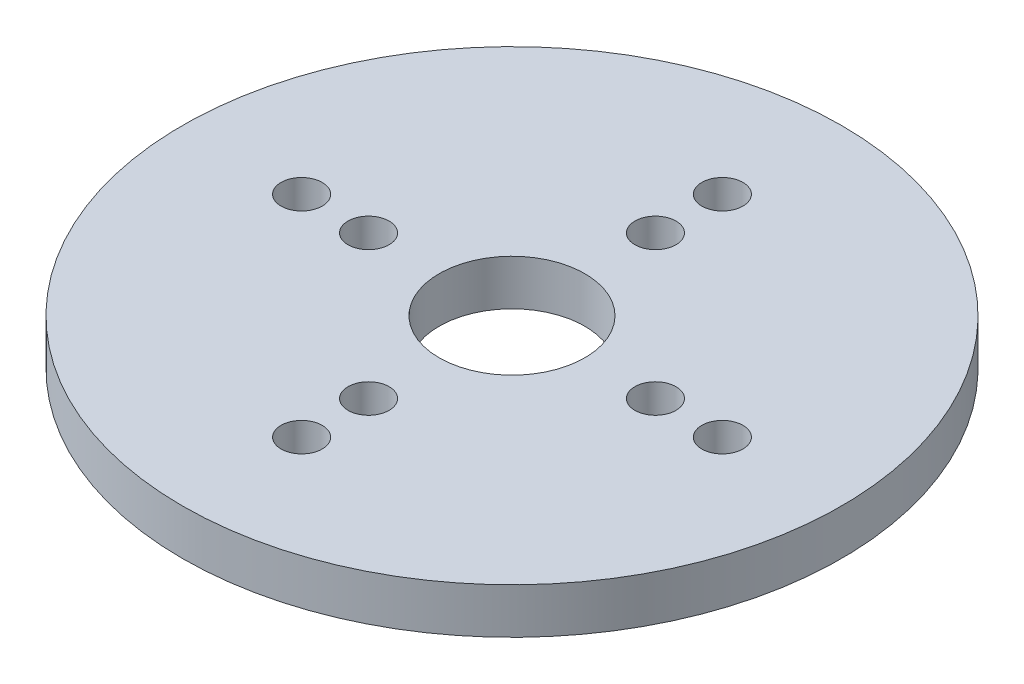
from build123d import *

# Parameters (mm, degrees)
SKETCH1_R           = 34.464858416
SKETCH1_R_2         = 2.15
SKETCH1_R_3         = 7.62
BOSS_EXTRUDE1_DEPTH = 4.7625


with BuildPart() as part:
    # Sketch1 → Boss-Extrude1 (new body)
    with BuildSketch(Plane(origin=(0, 0, 0), x_dir=(1, 0, 0), z_dir=(0, 1, 0))):
        with Locations((0, -8.264651725)):
            Circle(SKETCH1_R)
        with Locations((15, -8.264651725)):
            Circle(SKETCH1_R_2, mode=Mode.SUBTRACT)
        with Locations((22, -8.264651725)):
            Circle(SKETCH1_R_2, mode=Mode.SUBTRACT)
        with Locations((0, -23.264651725)):
            Circle(SKETCH1_R_2, mode=Mode.SUBTRACT)
        with Locations((0, -30.264651725)):
            Circle(SKETCH1_R_2, mode=Mode.SUBTRACT)
        with Locations((-15, -8.264651725)):
            Circle(SKETCH1_R_2, mode=Mode.SUBTRACT)
        with Locations((-22, -8.264651725)):
            Circle(SKETCH1_R_2, mode=Mode.SUBTRACT)
        with Locations((0, 6.735348275)):
            Circle(SKETCH1_R_2, mode=Mode.SUBTRACT)
        with Locations((0, 13.735348275)):
            Circle(SKETCH1_R_2, mode=Mode.SUBTRACT)
        with Locations((0, -8.264651725)):
            Circle(SKETCH1_R_3, mode=Mode.SUBTRACT)
    extrude(amount=BOSS_EXTRUDE1_DEPTH)


solid = part.part
